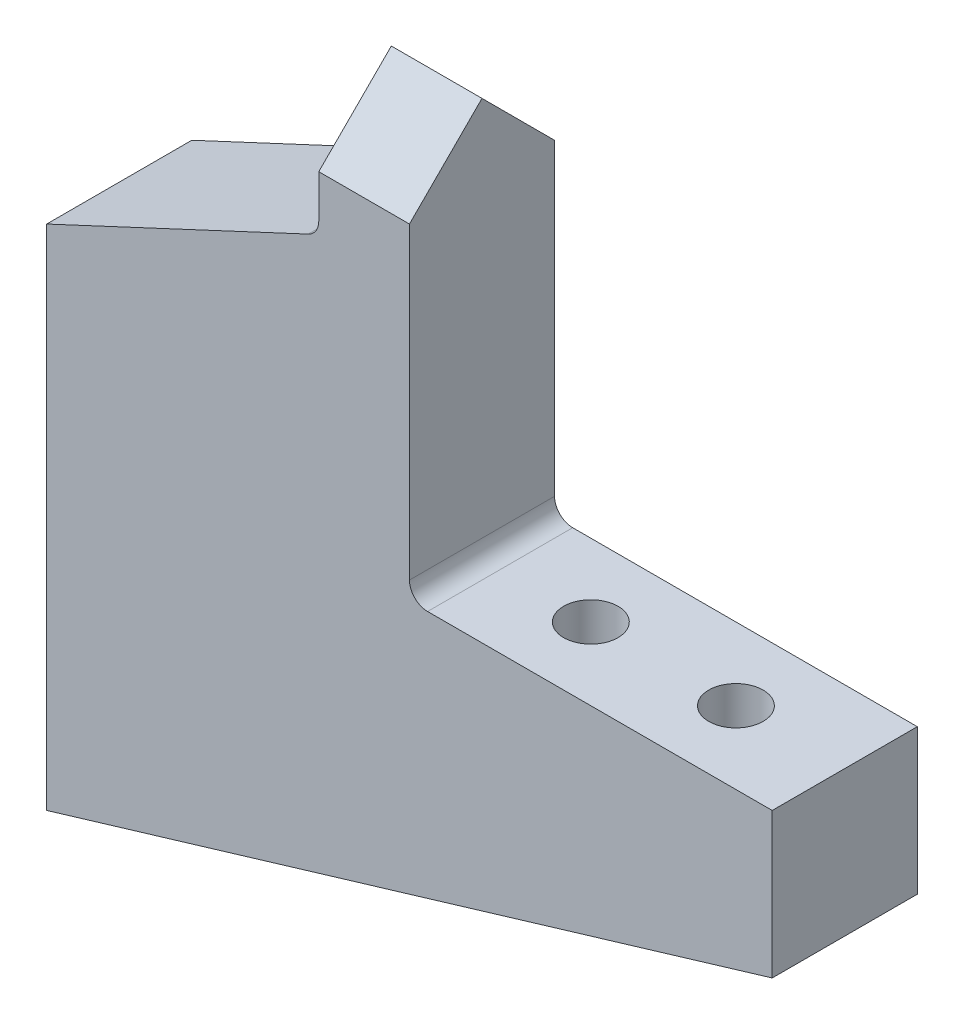
from build123d import *

# Parameters (mm, degrees)
BOSS_EXTRUDE1_DEPTH       = 8
CUT_EXTRUDE1_DEPTH        = 8
SKETCH7_R                 = 1.5
CUT_EXTRUDE4_DEPTH        = 6
SKETCH9_R                 = 2.5
CUT_EXTRUDE5_DEPTH        = 15
CUT_EXTRUDE2_DEPTH        = 21
CUT_EXTRUDE3_DEPTH        = 21
M2X0_4_TAPPED_HOLE1_D     = 1.6
M2X0_4_TAPPED_HOLE1_DEPTH = 8
M2X0_4_TAPPED_HOLE1_TIP   = 0.480688495
FILLET1_R                 = 1
FILLET2_R                 = 1


with BuildPart() as part:
    # Sketch1 → Boss-Extrude1 (new body)
    with BuildSketch(Plane.XY):
        Polygon((0, 0), (0, 42), (20, 42), (20, 20), (40, 20), (40, 12), align=None)
    extrude(amount=BOSS_EXTRUDE1_DEPTH)

    # Sketch2 → Cut-Extrude1 (cut)
    with BuildSketch(Plane.XY.offset(8)):
        Polygon((15, 42), (15, 35), (0, 28), (0, 42), align=None)
    extrude(amount=-CUT_EXTRUDE1_DEPTH, mode=Mode.SUBTRACT)

    # Sketch7 → Cut-Extrude4 (cut)
    with BuildSketch(Plane(origin=(0, 20, 0), x_dir=(1, 0, 0), z_dir=(0, 1, 0))):
        with Locations((34, -4)):
            Circle(SKETCH7_R)
        with Locations((26, -4)):
            Circle(SKETCH7_R)
    extrude(amount=-CUT_EXTRUDE4_DEPTH, mode=Mode.SUBTRACT)

    # Sketch9 → Cut-Extrude5 (cut, through all)
    with BuildSketch(Plane(origin=(0, 14, 0), x_dir=(1, 0, 0), z_dir=(0, 1, 0))):
        with Locations((34, -4)):
            Circle(SKETCH9_R)
        with Locations((26, -4)):
            Circle(SKETCH9_R)
    extrude(amount=-CUT_EXTRUDE5_DEPTH, mode=Mode.SUBTRACT)

    # Sketch5 → Cut-Extrude2 (cut, through all)
    with BuildSketch(Plane(origin=(20, 0, 0), x_dir=(0, 0, -1), z_dir=(1, 0, 0))):
        Polygon((-8, 42), (-4, 42), (-8, 38), align=None)
    extrude(amount=-CUT_EXTRUDE2_DEPTH, mode=Mode.SUBTRACT)

    # Sketch6 → Cut-Extrude3 (cut, through all)
    with BuildSketch(Plane(origin=(20, 0, 0), x_dir=(0, 0, -1), z_dir=(1, 0, 0))):
        Polygon((0, 42), (-4, 42), (0, 38), align=None)
    extrude(amount=-CUT_EXTRUDE3_DEPTH, mode=Mode.SUBTRACT)

    # M2x0.4 Tapped Hole1
    with Locations(Plane(origin=(0, 24, 4), x_dir=(0, 0, -1), z_dir=(-1, 0, 0))):
        with Locations((0, 0), (0, 8), (0, 16)):
            Hole(M2X0_4_TAPPED_HOLE1_D / 2, depth=M2X0_4_TAPPED_HOLE1_DEPTH)
            with Locations((0, 0, -(M2X0_4_TAPPED_HOLE1_DEPTH + M2X0_4_TAPPED_HOLE1_TIP / 2))):  # 118° drill point
                Cone(0, M2X0_4_TAPPED_HOLE1_D / 2, M2X0_4_TAPPED_HOLE1_TIP, mode=Mode.SUBTRACT)

    # Fillet1
    fillet1_edges = [part.edges().sort_by_distance(p)[0] for p in [
        (20, 20, 4),
    ]]
    fillet(fillet1_edges, radius=FILLET1_R)

    # Fillet2
    fillet2_edges = [part.edges().sort_by_distance(p)[0] for p in [
        (15, 35, 4),
    ]]
    fillet(fillet2_edges, radius=FILLET2_R)


solid = part.part
